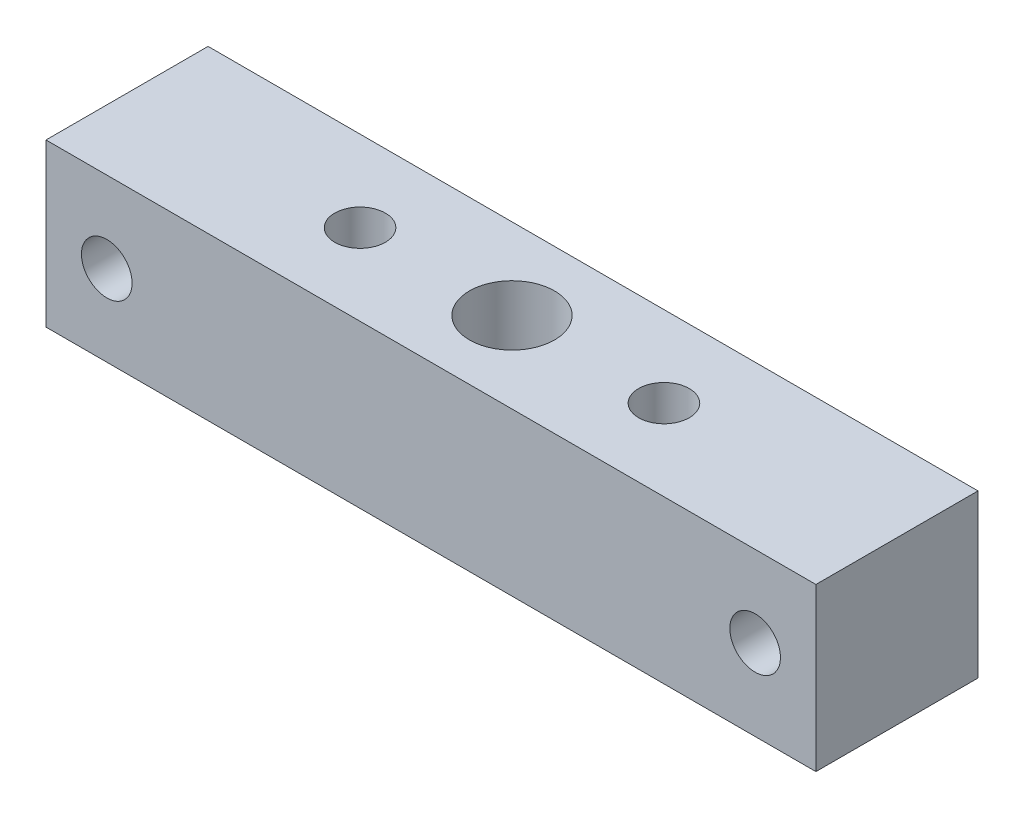
from build123d import *

# Parameters (mm, degrees)
SKETCH1_W                   = 38
SKETCH1_H                   = 8
BOSS_EXTRUDE1_DEPTH         = 8
TAP_DRILL_FOR_M5X0_8_TAP1_D = 4.2
TAP_DRILL_FOR_M3X0_5_TAP1_D = 2.5
TAP_DRILL_FOR_M3X0_5_TAP2_D = 2.5


with BuildPart() as part:
    # Sketch1 → Boss-Extrude1 (new body)
    with BuildSketch(Plane.XY):
        with Locations((19, 4)):
            Rectangle(SKETCH1_W, SKETCH1_H)
    extrude(amount=BOSS_EXTRUDE1_DEPTH)

    # Tap Drill for M5x0.8 Tap1 (through all)
    with Locations(Plane(origin=(0, 8, 0), x_dir=(-1, 0, 0), z_dir=(0, 1, 0))):
        with Locations((-19, 4)):
            Hole(TAP_DRILL_FOR_M5X0_8_TAP1_D / 2)

    # Tap Drill for M3x0.5 Tap1 (through all)
    with Locations(Plane(origin=(0, 0, 0), x_dir=(-1, 0, 0), z_dir=(0, 0, -1))):
        with Locations((-35, 4), (-3, 4)):
            Hole(TAP_DRILL_FOR_M3X0_5_TAP1_D / 2)

    # Tap Drill for M3x0.5 Tap2 (through all)
    with Locations(Plane(origin=(0, 8, 0), x_dir=(-1, 0, 0), z_dir=(0, 1, 0))):
        with Locations((-11.5, 4), (-26.5, 4)):
            Hole(TAP_DRILL_FOR_M3X0_5_TAP2_D / 2)


solid = part.part
